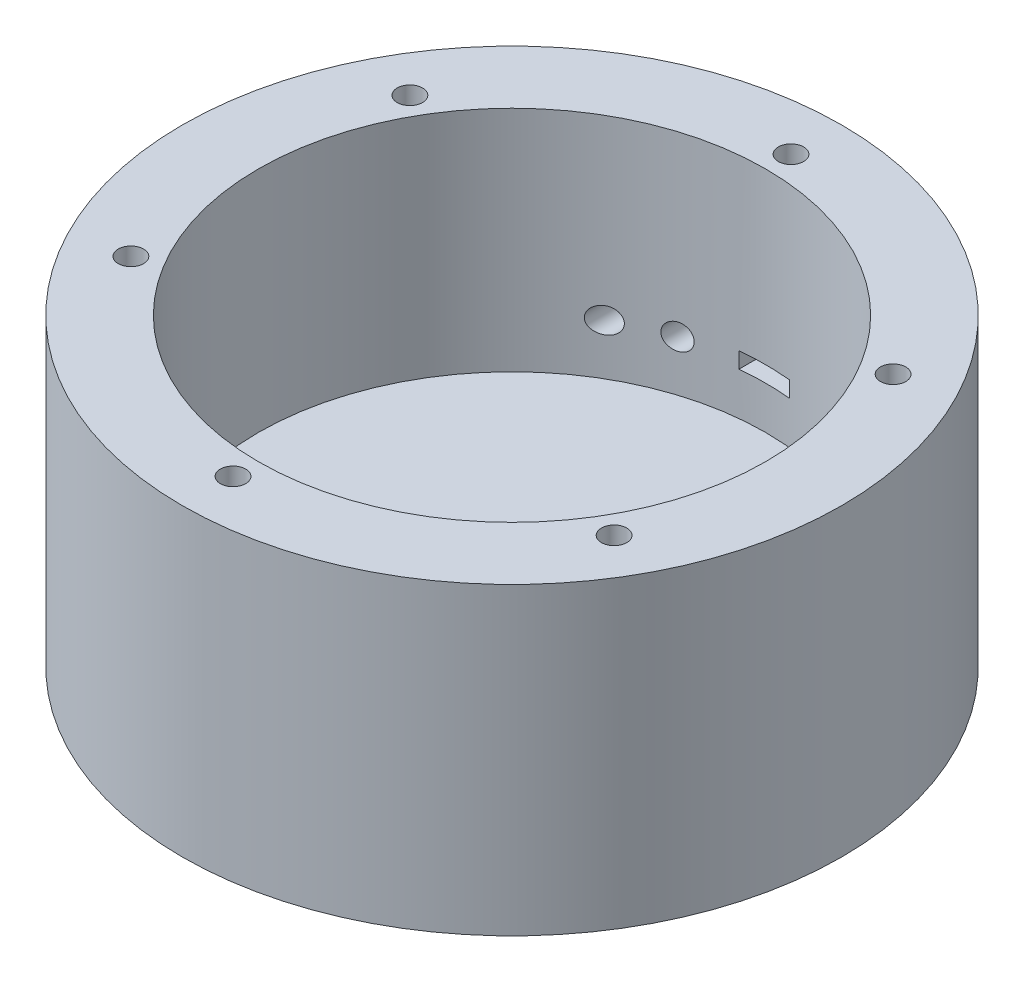
from build123d import *

# Parameters (mm, degrees)
CROQUIS1_R                 = 65
SALIENTE_EXTRUIR1_DEPTH    = 60
VACIADO1_T                 = -15
CROQUIS3_R                 = 2.5
CORTAR_EXTRUIR1_DEPTH      = 10
CORTAR_EXTRUIR2_REACH      = 190.992
CORTAR_EXTRUIR2_END_RADIUS = 50
CROQUIS4_R                 = 2.5
CROQUIS4_W                 = 10
CROQUIS4_H                 = 3.15


with BuildPart() as part:
    # Croquis1 → Saliente-Extruir1 (new body)
    with BuildSketch(Plane(origin=(0, 0, 0), x_dir=(1, 0, 0), z_dir=(0, 1, 0))):
        with Locations(Location((0, 0, 0), (0, 0, 270))):  # turned: the seam where the file's is
            Circle(CROQUIS1_R)
    extrude(amount=SALIENTE_EXTRUIR1_DEPTH)

    # Vaciado1
    vaciado1_openings = [part.faces().sort_by_distance(p)[0] for p in [
        (0, 60, 0),
    ]]
    offset(amount=VACIADO1_T, openings=vaciado1_openings, kind=Kind.INTERSECTION)

    # Croquis3 → Cortar-Extruir1 (cut)
    with BuildSketch(Plane(origin=(0, 60, 0), x_dir=(1, 0, 0), z_dir=(0, 1, 0))):
        with Locations(Location((0, 55, 0), (0, 0, 270))):  # turned: the seam where the file's is
            Circle(CROQUIS3_R)
        with Locations(Location((47.631397208, 27.5, 0), (0, 0, 270))):  # turned: the seam where the file's is
            Circle(CROQUIS3_R)
        with Locations(Location((47.631397208, -27.5, 0), (0, 0, 270))):  # turned: the seam where the file's is
            Circle(CROQUIS3_R)
        with Locations(Location((0, -55, 0), (0, 0, 270))):  # turned: the seam where the file's is
            Circle(CROQUIS3_R)
        with Locations(Location((-47.631397208, -27.5, 0), (0, 0, 270))):  # turned: the seam where the file's is
            Circle(CROQUIS3_R)
        with Locations(Location((-47.631397208, 27.5, 0), (0, 0, 270))):  # turned: the seam where the file's is
            Circle(CROQUIS3_R)
    extrude(amount=-CORTAR_EXTRUIR1_DEPTH, mode=Mode.SUBTRACT)

    # Cortar-Extruir2: up to this cylinder (the profile starts outside it)
    cortar_extruir2_end = Plane(origin=(0, 25, 0), z_dir=(0, -1, 0)) * Cylinder(CORTAR_EXTRUIR2_END_RADIUS, 482.984, mode=Mode.PRIVATE)
    # Croquis4 → Cortar-Extruir2 (cut, up to the surface)
    with BuildSketch(Plane(origin=(6.129951323, -2.103381064, -123.992328347), x_dir=(1, 0, 0), z_dir=(0, 0, 1)), mode=Mode.PRIVATE) as cortar_extruir2_sk1:
        with Locations(Location((-21.129951323, 27.103381064, 0), (0, 0, 180))):  # turned: the seam where the file's is
            Circle(CROQUIS4_R)
    cortar_extruir2_tool1 = extrude(cortar_extruir2_sk1.sketch, amount=CORTAR_EXTRUIR2_REACH, mode=Mode.PRIVATE) - cortar_extruir2_end
    add(cortar_extruir2_tool1.solids().sort_by_distance((-15, 25, -123.992328))[0], mode=Mode.SUBTRACT)
    # Croquis4 → Cortar-Extruir2 (cut, up to the surface)
    with BuildSketch(Plane(origin=(6.129951323, -2.103381064, -123.992328347), x_dir=(1, 0, 0), z_dir=(0, 0, 1)), mode=Mode.PRIVATE) as cortar_extruir2_sk2:
        with Locations(Location((-31.129951323, 27.103381064, 0), (0, 0, 180))):  # turned: the seam where the file's is
            Circle(CROQUIS4_R)
    cortar_extruir2_tool2 = extrude(cortar_extruir2_sk2.sketch, amount=CORTAR_EXTRUIR2_REACH, mode=Mode.PRIVATE) - cortar_extruir2_end
    add(cortar_extruir2_tool2.solids().sort_by_distance((-25, 25, -123.992328))[0], mode=Mode.SUBTRACT)
    # Croquis4 → Cortar-Extruir2 (cut, up to the surface)
    with BuildSketch(Plane(origin=(6.129951323, -2.103381064, -123.992328347), x_dir=(1, 0, 0), z_dir=(0, 0, 1)), mode=Mode.PRIVATE) as cortar_extruir2_sk3:
        with Locations((-6.129951323, 27.103381064)):
            Rectangle(CROQUIS4_W, CROQUIS4_H)
    cortar_extruir2_tool3 = extrude(cortar_extruir2_sk3.sketch, amount=CORTAR_EXTRUIR2_REACH, mode=Mode.PRIVATE) - cortar_extruir2_end
    add(cortar_extruir2_tool3.solids().sort_by_distance((0, 25, -123.992328))[0], mode=Mode.SUBTRACT)


solid = part.part
